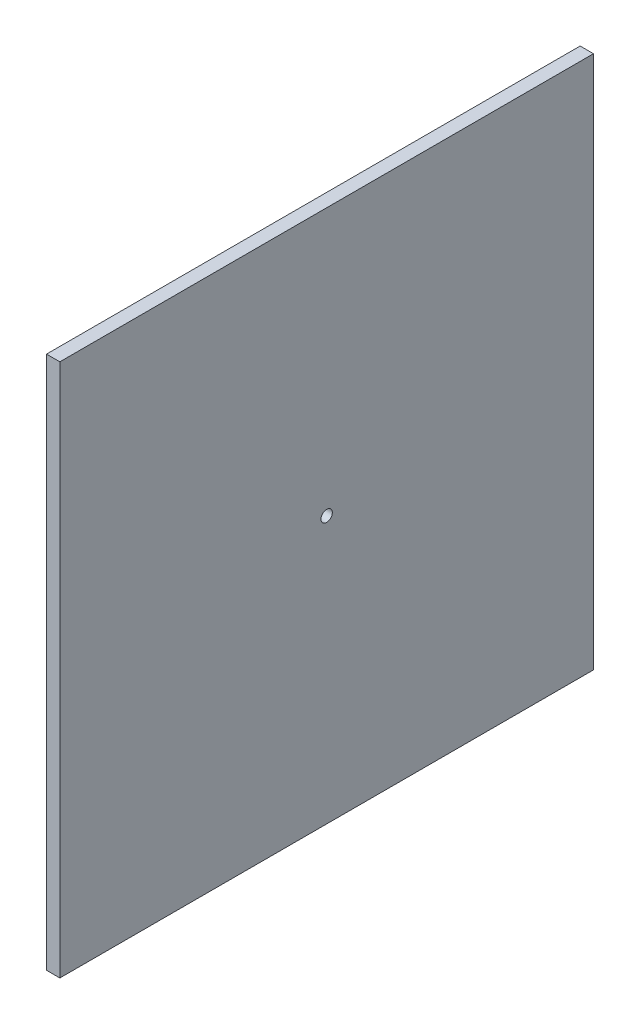
from build123d import *

# Parameters (mm, degrees)
SKETCH1_W           = 400
SKETCH1_H           = 400
SKETCH1_R           = 4.25
BOSS_EXTRUDE1_DEPTH = 10


with BuildPart() as part:
    # Sketch1 → Boss-Extrude1 (new body)
    with BuildSketch(Plane(origin=(0, 0, 0), x_dir=(0, 0, -1), z_dir=(1, 0, 0))):
        Rectangle(SKETCH1_W, SKETCH1_H)
        Circle(SKETCH1_R, mode=Mode.SUBTRACT)
    extrude(amount=BOSS_EXTRUDE1_DEPTH)


solid = part.part
